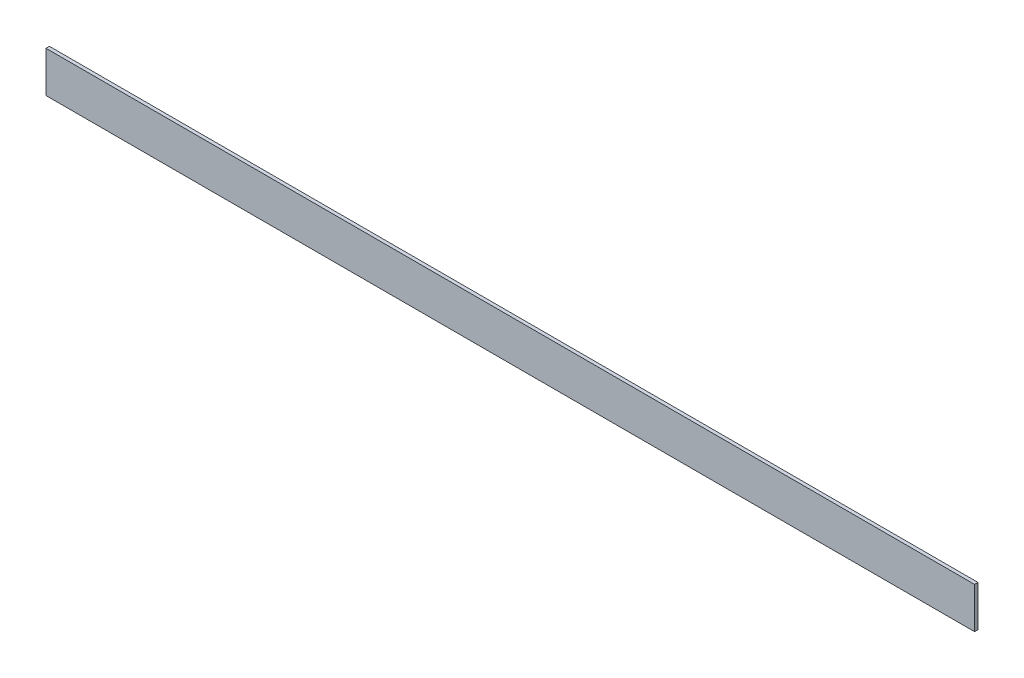
from build123d import *

# Parameters (mm, degrees)
SKETCH1_W           = 6.35
SKETCH1_H           = 76.2
BOSS_EXTRUDE1_DEPTH = 1727.2


with BuildPart() as part:
    # Sketch1 → Boss-Extrude1 (new body)
    with BuildSketch(Plane(origin=(0, 0, 0), x_dir=(0, 0, -1), z_dir=(1, 0, 0))):
        Rectangle(SKETCH1_W, SKETCH1_H)
    extrude(amount=BOSS_EXTRUDE1_DEPTH)


solid = part.part
